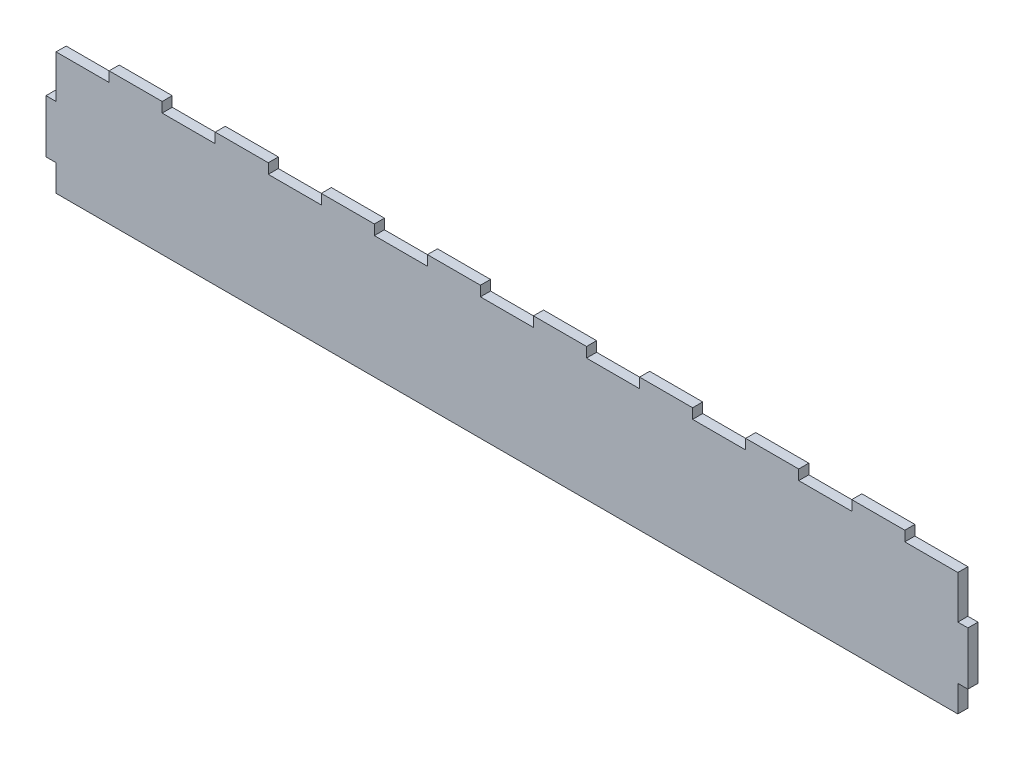
from build123d import *

# Parameters (mm, degrees)
BOSS_EXTRUDE1_DEPTH = 4.826
SKETCH3_W           = 441.452
SKETCH3_H           = 63.5
CUT_EXTRUDE1_DEPTH  = 5.826


with BuildPart() as part:
    # Sketch2 → Boss-Extrude1 (new body)
    with BuildSketch(Plane.XY):
        Polygon((0, 122.174), (0, 101.6), (-4.826, 101.6), (-4.826, 76.2), (0, 76.2), (0, 50.8), (-4.826, 50.8), (-4.826, 25.4), (0, 25.4), (0, 0), (431.8, 0), (431.8, 25.4), (436.626, 25.4), (436.626, 50.8), (431.8, 50.8), (431.8, 76.2), (436.626, 76.2), (436.626, 101.6), (431.8, 101.6), (431.8, 122.174), (406.4, 122.174), (406.4, 127), (381, 127), (381, 122.174), (355.6, 122.174), (355.6, 127), (330.2, 127), (330.2, 122.174), (304.8, 122.174), (304.8, 127), (279.4, 127), (279.4, 122.174), (254, 122.174), (254, 127), (228.6, 127), (228.6, 122.174), (203.2, 122.174), (203.2, 127), (177.8, 127), (177.8, 122.174), (152.4, 122.174), (152.4, 127), (127, 127), (127, 122.174), (101.6, 122.174), (101.6, 127), (76.2, 127), (76.2, 122.174), (50.8, 122.174), (50.8, 127), (25.4, 127), (25.4, 122.174), align=None)
    extrude(amount=BOSS_EXTRUDE1_DEPTH)

    # Sketch3 → Cut-Extrude1 (cut, through all)
    with BuildSketch(Plane(origin=(0, 0, 0), x_dir=(-1, 0, 0), z_dir=(0, 0, -1))):
        with Locations((-215.9, 31.75)):
            Rectangle(SKETCH3_W, SKETCH3_H)
    extrude(amount=-CUT_EXTRUDE1_DEPTH, mode=Mode.SUBTRACT)


solid = part.part
